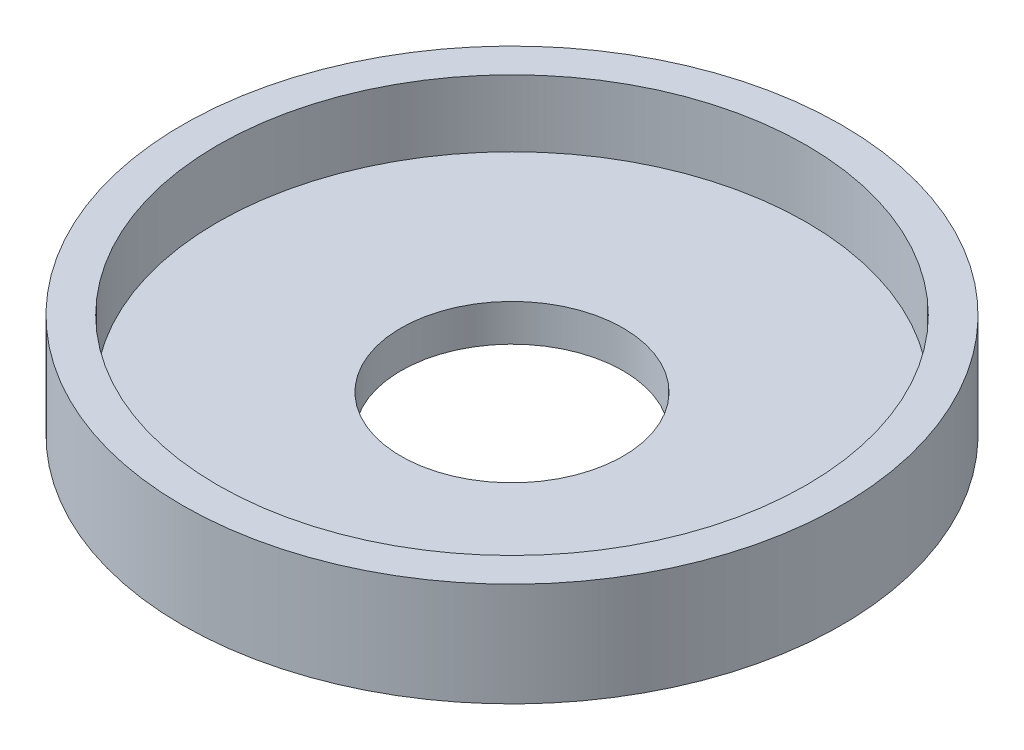
from build123d import *


with BuildPart() as part:
    # Skizze1 → Rotation1 (revolve)
    with BuildSketch(Plane(origin=(0, 0, 0), x_dir=(0, 0, -1), z_dir=(1, 0, 0))):
        Polygon((-6, 0), (-17.8, 0), (-17.8, 5.6), (-15.9, 5.6), (-15.9, 2), (-6, 2), align=None)
    revolve(axis=Axis((0, 0, 0), (0, 1, 0)))


solid = part.part
